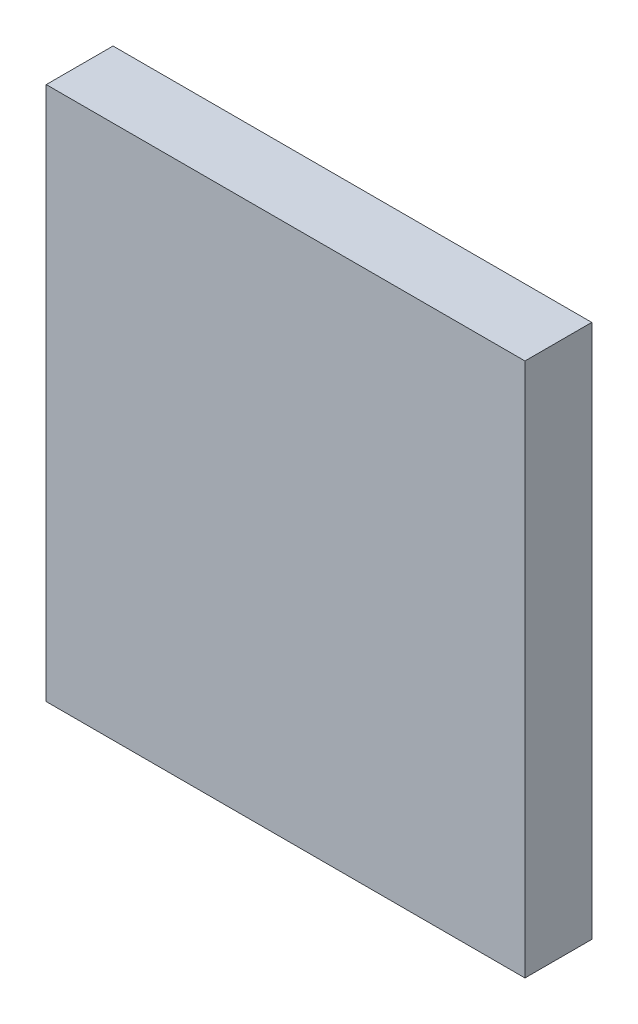
from build123d import *

# Parameters (mm, degrees)
SKETCH_1_W      = 43
SKETCH_1_H      = 48
EXTRUDE_1_DEPTH = 6


with BuildPart() as part:
    # Эскиз1 → Бобышка-Вытянуть1 (new body)
    with BuildSketch(Plane.XY):
        with Locations((0, 24)):
            Rectangle(SKETCH_1_W, SKETCH_1_H)
    extrude(amount=EXTRUDE_1_DEPTH)


solid = part.part
